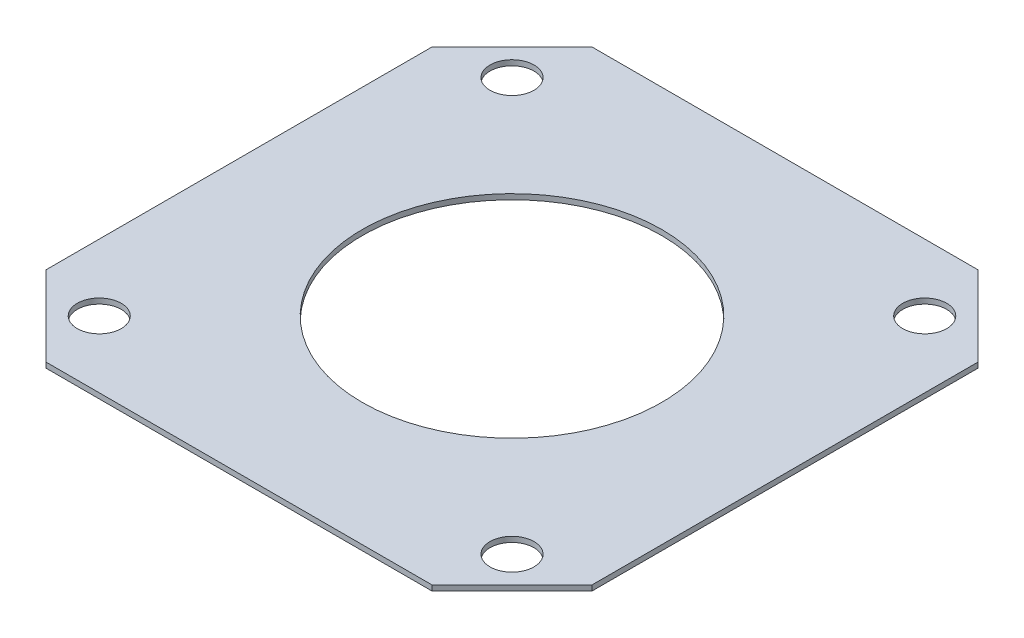
from build123d import *

# Parameters (mm, degrees)
SKETCH1_W           = 41
SKETCH1_H           = 41
SKETCH1_R           = 11.25
SKETCH1_R_2         = 1.65
BOSS_EXTRUDE1_DEPTH = 0.4
CHAMFER1_SIZE       = 6


with BuildPart() as part:
    # Sketch1 → Boss-Extrude1 (new body)
    with BuildSketch(Plane(origin=(0, 0, 0), x_dir=(-1, 0, 0), z_dir=(0, 1, 0))):
        Rectangle(SKETCH1_W, SKETCH1_H)
        Circle(SKETCH1_R, mode=Mode.SUBTRACT)
        with Locations((15.5, 15.5)):
            Circle(SKETCH1_R_2, mode=Mode.SUBTRACT)
        with Locations((-15.5, 15.5)):
            Circle(SKETCH1_R_2, mode=Mode.SUBTRACT)
        with Locations((-15.5, -15.5)):
            Circle(SKETCH1_R_2, mode=Mode.SUBTRACT)
        with Locations((15.5, -15.5)):
            Circle(SKETCH1_R_2, mode=Mode.SUBTRACT)
    extrude(amount=BOSS_EXTRUDE1_DEPTH)

    # Chamfer1
    chamfer1_edges = [part.edges().sort_by_distance(p)[0] for p in [
        (-20.5, 0.2, -20.5),
        (20.5, 0.2, -20.5),
        (20.5, 0.2, 20.5),
        (-20.5, 0.2, 20.5),
    ]]
    chamfer(chamfer1_edges, length=CHAMFER1_SIZE)


solid = part.part
